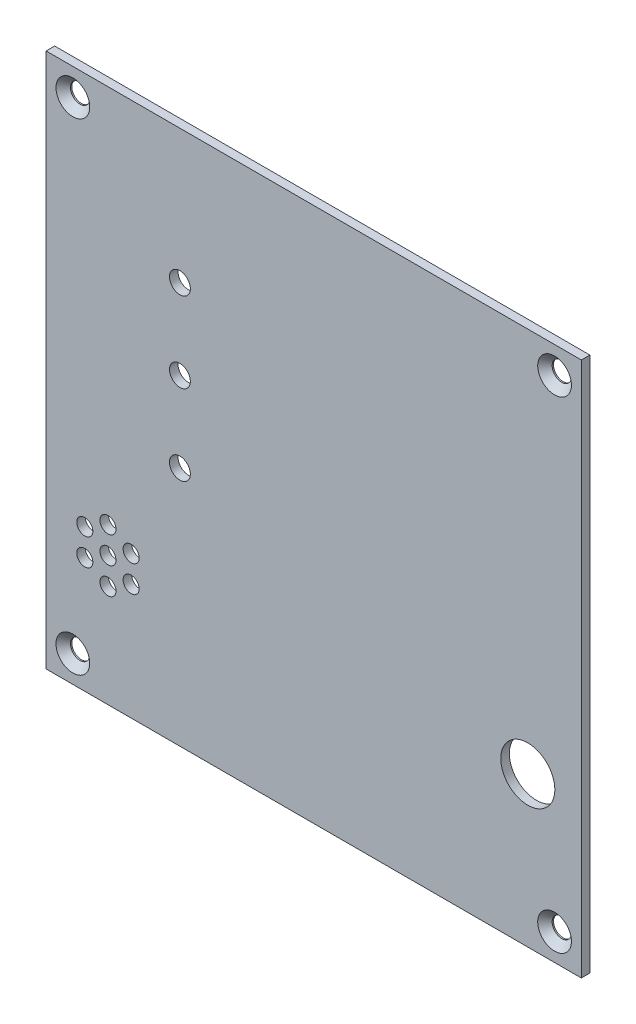
from build123d import *

# Parameters (mm, degrees)
ESQUISSE1_W                                 = 100
ESQUISSE1_H                                 = 100
BOSS_EXTRU_1_DEPTH                          = 1.6
FRAISAGE_POUR_VIS_T_TE_FRAIS_E_M31_AT_COUNT = 2
FRAISAGE_POUR_VIS_T_TE_FRAIS_E_M31_AT_PITCH = 90
FRAISAGE_POUR_VIS_T_TE_FRAIS_E_M31_2_COUNT  = 2
FRAISAGE_POUR_VIS_T_TE_FRAIS_E_M31_2_PITCH  = 127.279220614
FRAISAGE_POUR_VIS_T_TE_FRAIS_E_M31_3_COUNT  = 2
FRAISAGE_POUR_VIS_T_TE_FRAIS_E_M31_3_PITCH  = 90
ESQUISSE4_R                                 = 5.05
ESQUISSE4_R_2                               = 1.5
ESQUISSE4_R_3                               = 1.95
ENL_V_MAT_EXTRU_1_DEPTH                     = 2.6


with BuildPart() as part:
    # Esquisse1 → Boss.-Extru.1 (new body)
    with BuildSketch(Plane.XY):
        with Locations((50, 50)):
            Rectangle(ESQUISSE1_W, ESQUISSE1_H)
    extrude(amount=BOSS_EXTRU_1_DEPTH)

    # Esquisse3 → Fraisage pour vis à tête fraisée M31 (revolve, cut)
    with BuildSketch(Plane(origin=(5, 95, 1.6), x_dir=(0, -1, 0), z_dir=(1, 0, 0))):
        Polygon((0, 0), (0, 1.6), (1.8, 1.6), (1.8, 1.35), (3.15, 0), align=None)
    fraisage_pour_vis_t_te_frais_e_m31 = revolve(axis=Axis((5, 95, 7.95), (0, 0, -1)), mode=Mode.SUBTRACT)

    # Fraisage pour vis à tête fraisée M31 at: Fraisage pour vis à tête fraisée M31 ×2
    with Locations(*[(i * FRAISAGE_POUR_VIS_T_TE_FRAIS_E_M31_AT_PITCH, 0, 0) for i in range(1, FRAISAGE_POUR_VIS_T_TE_FRAIS_E_M31_AT_COUNT)]):
        add(fraisage_pour_vis_t_te_frais_e_m31, mode=Mode.SUBTRACT)

    # Fraisage pour vis _ t_te frais_e M31 2: Fraisage pour vis à tête fraisée M31 ×2
    with Locations(*[Vector(0.707106781, -0.707106781, 0) * (i * FRAISAGE_POUR_VIS_T_TE_FRAIS_E_M31_2_PITCH) for i in range(1, FRAISAGE_POUR_VIS_T_TE_FRAIS_E_M31_2_COUNT)]):
        add(fraisage_pour_vis_t_te_frais_e_m31, mode=Mode.SUBTRACT)

    # Fraisage pour vis _ t_te frais_e M31 3: Fraisage pour vis à tête fraisée M31 ×2
    with Locations(*[(0, -i * FRAISAGE_POUR_VIS_T_TE_FRAIS_E_M31_3_PITCH, 0) for i in range(1, FRAISAGE_POUR_VIS_T_TE_FRAIS_E_M31_3_COUNT)]):
        add(fraisage_pour_vis_t_te_frais_e_m31, mode=Mode.SUBTRACT)

    # Esquisse4 → Enlèv. mat.-Extru.1 (cut, through all)
    with BuildSketch(Plane.XY.offset(1.6)):
        with Locations((90, 28)):
            Circle(ESQUISSE4_R)
        with Locations((11.557, 24.13)):
            Circle(ESQUISSE4_R_2)
        with Locations((11.557, 29.13)):
            Circle(ESQUISSE4_R_2)
        with Locations((15.887127019, 26.63)):
            Circle(ESQUISSE4_R_2)
        with Locations((15.887127019, 21.63)):
            Circle(ESQUISSE4_R_2)
        with Locations((11.557, 19.13)):
            Circle(ESQUISSE4_R_2)
        with Locations((7.226872981, 21.63)):
            Circle(ESQUISSE4_R_2)
        with Locations((7.226872981, 26.63)):
            Circle(ESQUISSE4_R_2)
        with Locations((25, 75)):
            Circle(ESQUISSE4_R_3)
        with Locations((25, 60)):
            Circle(ESQUISSE4_R_3)
        with Locations((25, 45)):
            Circle(ESQUISSE4_R_3)
    extrude(amount=-ENL_V_MAT_EXTRU_1_DEPTH, mode=Mode.SUBTRACT)


solid = part.part
